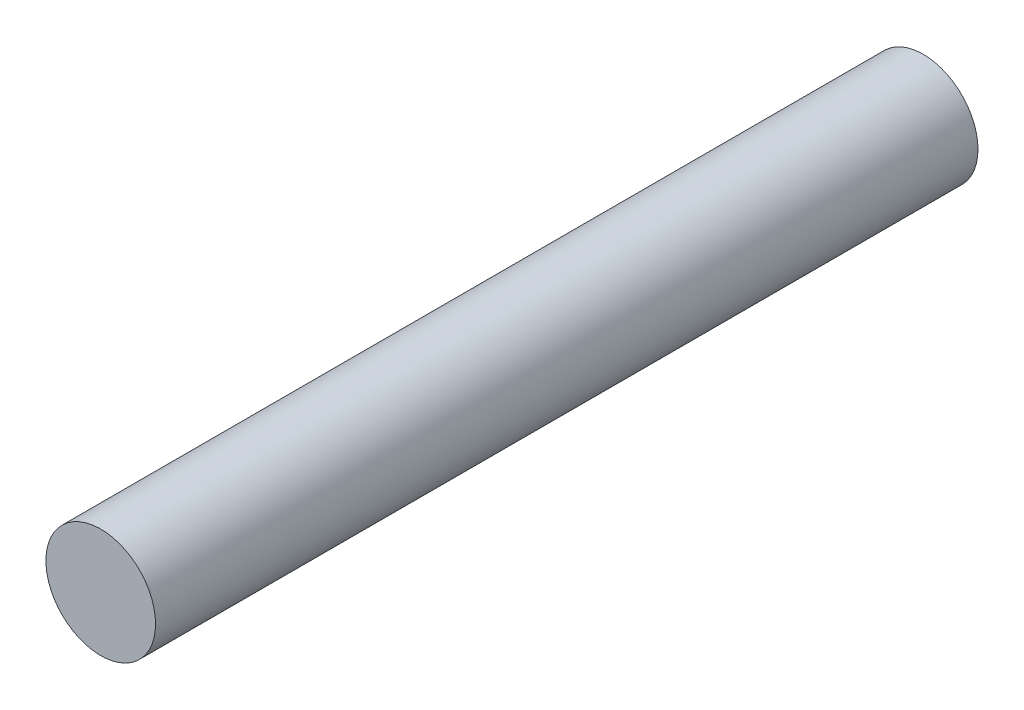
from build123d import *

# Parameters (mm, degrees)
SKETCH_1_R      = 2
EXTRUDE_1_DEPTH = 30


with BuildPart() as part:
    # 草图1 → 凸台-拉伸1 (new body)
    with BuildSketch(Plane.XY):
        Circle(SKETCH_1_R)
    extrude(amount=EXTRUDE_1_DEPTH)


solid = part.part
